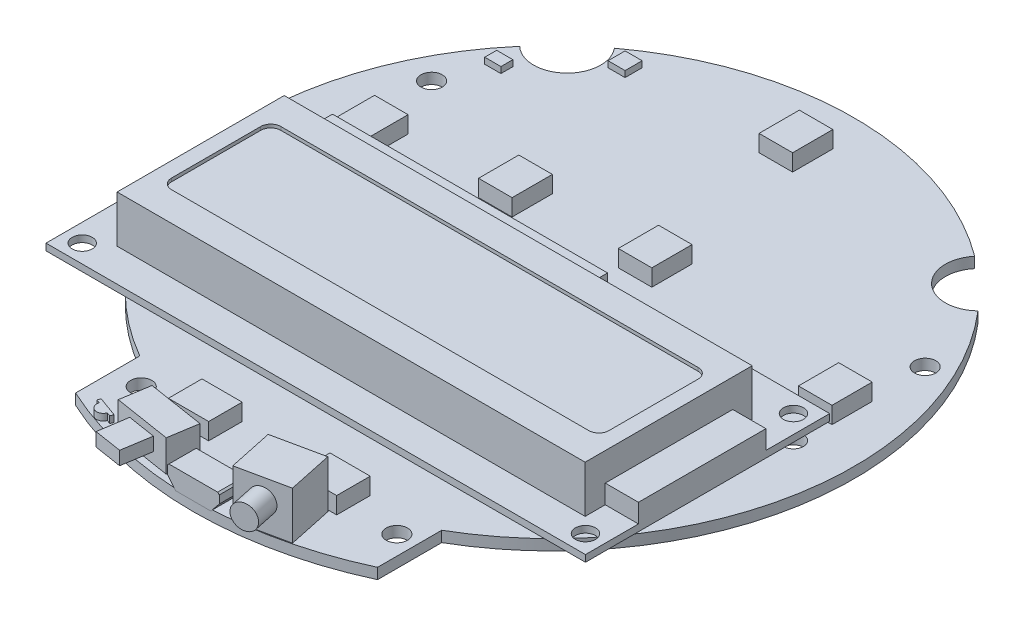
from build123d import *

# Parameters (mm, degrees)
BOSS_EXTRUDE_START                   = 29.4
PCB_AREA_R                           = 1.5
PCB_AREA_R_2                         = 1.59
BOSS_EXTRUDE_PCB_DEPTH               = 1.6
BOSS_EXTRUDE_START_2                 = 33.5
LCD_AREA_W                           = 80.4
LCD_AREA_H                           = 36.4
LCD_AREA_R                           = 1.5
BOSS_EXTRUDE_LCD_PCB_DEPTH           = 1
BOSS_EXTRUDE_START_3                 = 36.6
LCD_AREA_3_W                         = 41
LCD_AREA_3_H                         = 3.5
BOSS_EXTRUDE_LCD_HEADER_DEPTH        = 5.6
BOSS_EXTRUDE_START_4                 = 34.5
LCD_AREA_4_W                         = 4.95
LCD_AREA_4_H                         = 19
BOSS_EXTRUDE_LCD_BACKLIGHT_DEPTH     = 2.8
LCD_AREA_5_W                         = 69.75
LCD_AREA_5_H                         = 24.9
BOSS_EXTRUDE_LCD_CASING_DEPTH        = 7
CUT_EXTRUDE_START                    = 41.5
CUT_EXTRUDE_LCD_SCREEN_DEPTH         = 0.5
BOSS_EXTRUDE_START_5                 = 31
PCB_COMPONENTS_3_W                   = 5.00000016
PCB_COMPONENTS_3_H                   = 6.0000007
PCB_COMPONENTS_3_W_2                 = 6.0000007
PCB_COMPONENTS_3_H_2                 = 5.00000016
BOSS_EXTRUDE_LEDS_DEPTH              = 2.5
BOSS_EXTRUDE_CHARGING_LED_DEPTH      = 1
PCB_COMPONENTS_5_W                   = 2.413
PCB_COMPONENTS_5_H                   = 1.778
BOSS_EXTRUDE_LIGHT_SENSOR_DEPTH      = 0.91
PCB_COMPONENTS_6_W                   = 2.54
PCB_COMPONENTS_6_H                   = 2.54
BOSS_EXTRUDE_TEMP_SENSOR_DEPTH       = 0.91
BOSS_EXTRUDE_POWER_SWITCH_BASE_DEPTH = 4.7
BOSS_EXTRUDE_START_6                 = 32.6
BOSS_EXTRUDE_POWER_SWITCH_DEPTH      = 2
BOSS_EXTRUDE_START_7                 = 53.5
BOSS_EXTRUDE_USB_CONNECTOR_DEPTH     = 4.06
BOSS_EXTRUDE_BUTTON_BASE_DEPTH       = 7.1
BUTTON_CIRCLE_R                      = 1.8
BOSS_EXTRUDE_BUTTON_DEPTH            = 3.55


with BuildPart() as part:
    # PCB area → Boss-Extrude PCB (new body)
    with BuildSketch(Plane(origin=(0, 0, 0), x_dir=(1, 0, 0), z_dir=(0, 1, 0)).offset(BOSS_EXTRUDE_START)):
        with BuildLine():
            Line((-22.5, -48.538644398), (-22.5, -38.97114317))
            ThreePointArc((-22.5, -38.97114317), (-44.358674104, -7.570206849), (-34.1516032, 29.303037366))
            ThreePointArc((-34.1516032, 29.303037366), (-27.279934403, 29.254148065), (-26.849361228, 36.112488167))
            ThreePointArc((-26.849361228, 36.112488167), (0, 45), (26.849361228, 36.112488167))
            ThreePointArc((26.849361228, 36.112488167), (27.279934402, 29.254148065), (34.1516032, 29.303037366))
            ThreePointArc((34.1516032, 29.303037366), (44.358674104, -7.570206849), (22.5, -38.97114317))
            Line((22.5, -38.97114317), (22.5, -48.538644398))
            ThreePointArc((22.5, -48.538644398), (0, -53.5), (-22.5, -48.538644398))
        make_face()
        with Locations((-37.85, -1.2)):
            Circle(PCB_AREA_R, mode=Mode.SUBTRACT)
        with Locations((37.15, -1.2)):
            Circle(PCB_AREA_R, mode=Mode.SUBTRACT)
        with Locations((-18.44, -42.82)):
            Circle(PCB_AREA_R_2, mode=Mode.SUBTRACT)
        with Locations((19.66, -42.82)):
            Circle(PCB_AREA_R_2, mode=Mode.SUBTRACT)
        with Locations((-36.25, 18.27)):
            Circle(PCB_AREA_R_2, mode=Mode.SUBTRACT)
        with Locations((37.44, 18.14)):
            Circle(PCB_AREA_R_2, mode=Mode.SUBTRACT)
    extrude(amount=BOSS_EXTRUDE_PCB_DEPTH)



with BuildPart() as body_2:
    # LCD area → Boss-Extrude LCD PCB (new body)
    with BuildSketch(Plane(origin=(0, 0, 0), x_dir=(1, 0, 0), z_dir=(0, 1, 0)).offset(BOSS_EXTRUDE_START_2)):
        with Locations((-0.35, -16.7)):
            Rectangle(LCD_AREA_W, LCD_AREA_H)
        with Locations((-37.85, -1.2)):
            Circle(LCD_AREA_R, mode=Mode.SUBTRACT)
        with Locations((37.15, -1.2)):
            Circle(LCD_AREA_R, mode=Mode.SUBTRACT)
        with Locations((37.15, -32.2)):
            Circle(LCD_AREA_R, mode=Mode.SUBTRACT)
        with Locations((-37.85, -32.2)):
            Circle(LCD_AREA_R, mode=Mode.SUBTRACT)
    extrude(amount=BOSS_EXTRUDE_LCD_PCB_DEPTH)


with BuildPart() as part_1:
    add(part.part)

    add(body_2.part)  # Boss-Extrude LCD header merges body 2
    # LCD area_3 → Boss-Extrude LCD header (add)
    with BuildSketch(Plane(origin=(0, 0, 0), x_dir=(1, 0, 0), z_dir=(0, 1, 0)).offset(BOSS_EXTRUDE_START_3)):
        with Locations((-13.25, -0.75)):
            Rectangle(LCD_AREA_3_W, LCD_AREA_3_H)
    extrude(amount=-BOSS_EXTRUDE_LCD_HEADER_DEPTH)

    # LCD area_4 → Boss-Extrude LCD backlight (add)
    with BuildSketch(Plane(origin=(0, 0, 0), x_dir=(1, 0, 0), z_dir=(0, 1, 0)).offset(BOSS_EXTRUDE_START_4)):
        with Locations((37.375, -17.5)):
            Rectangle(LCD_AREA_4_W, LCD_AREA_4_H)
    extrude(amount=BOSS_EXTRUDE_LCD_BACKLIGHT_DEPTH)

    # LCD area_5 → Boss-Extrude LCD casing (add)
    with BuildSketch(Plane(origin=(0, 0, 0), x_dir=(1, 0, 0), z_dir=(0, 1, 0)).offset(BOSS_EXTRUDE_START_4)):
        with Locations((0.025, -17.55)):
            Rectangle(LCD_AREA_5_W, LCD_AREA_5_H)
    extrude(amount=BOSS_EXTRUDE_LCD_CASING_DEPTH)

    # LCD area_6 → Cut-Extrude LCD screen (cut)
    with BuildSketch(Plane(origin=(0, 0, 0), x_dir=(1, 0, 0), z_dir=(0, 1, 0)).offset(CUT_EXTRUDE_START)):
        with BuildLine():
            Line((31.1, -25.65), (-31.1, -25.65))
            ThreePointArc((-31.1, -25.65), (-32.160660172, -25.210660172), (-32.6, -24.15))
            Line((-32.6, -24.15), (-32.6, -10.85))
            ThreePointArc((-32.6, -10.85), (-32.160660172, -9.789339828), (-31.1, -9.35))
            Line((-31.1, -9.35), (31.1, -9.35))
            ThreePointArc((31.1, -9.35), (32.160660172, -9.789339828), (32.6, -10.85))
            Line((32.6, -10.85), (32.6, -24.15))
            ThreePointArc((32.6, -24.15), (32.160660172, -25.210660172), (31.1, -25.65))
        make_face()
    extrude(amount=-CUT_EXTRUDE_LCD_SCREEN_DEPTH, mode=Mode.SUBTRACT)

    # PCB components_3 → Boss-Extrude LEDs (add)
    with BuildSketch(Plane(origin=(0, 0, 0), x_dir=(1, 0, 0), z_dir=(0, 1, 0)).offset(BOSS_EXTRUDE_START_5)):
        with Locations((-33.64490509, 6.662364904)):
            Rectangle(PCB_COMPONENTS_3_W, PCB_COMPONENTS_3_H)
        with Locations((-9.402413685, -42.304616346)):
            Rectangle(PCB_COMPONENTS_3_W_2, PCB_COMPONENTS_3_H_2)
        with Locations((9.693556469, -42.318837537)):
            Rectangle(PCB_COMPONENTS_3_W_2, PCB_COMPONENTS_3_H_2)
        with Locations((-15.185287476, 9.703655188)):
            Rectangle(PCB_COMPONENTS_3_W, PCB_COMPONENTS_3_H)
        with Locations((4.286094666, 11.05569071)):
            Rectangle(PCB_COMPONENTS_3_W, PCB_COMPONENTS_3_H)
        with Locations((35.455097198, 6.737369482)):
            Rectangle(PCB_COMPONENTS_3_W, PCB_COMPONENTS_3_H)
        with Locations((-0.07787323, 36.401340429)):
            Rectangle(PCB_COMPONENTS_3_W, PCB_COMPONENTS_3_H)
    extrude(amount=BOSS_EXTRUDE_LEDS_DEPTH)

    # PCB components → Boss-Extrude charging LED (add)
    with BuildSketch(Plane(origin=(0, 0, 0), x_dir=(1, 0, 0), z_dir=(0, 1, 0)).offset(BOSS_EXTRUDE_START_5)):
        with BuildLine():
            Line((-19.015338568, -48.848593014), (-18.451523006, -49.053805147))
            ThreePointArc((-18.451523006, -49.053805147), (-17.853850615, -50.335517952), (-16.572137811, -49.737845561))
            Line((-16.572137811, -49.737845561), (-16.008322255, -49.943057676))
            Line((-16.008322255, -49.943057676), (-15.837312152, -49.473211377))
            Line((-15.837312152, -49.473211377), (-18.844328464, -48.378746715))
            Line((-18.844328464, -48.378746715), (-19.015338568, -48.848593014))
        make_face()
    extrude(amount=BOSS_EXTRUDE_CHARGING_LED_DEPTH)

    # PCB components_5 → Boss-Extrude light sensor (add)
    with BuildSketch(Plane(origin=(0, 0, 0), x_dir=(1, 0, 0), z_dir=(0, 1, 0)).offset(BOSS_EXTRUDE_START_5)):
        with Locations((-33.235496521, 25.269289599)):
            Rectangle(PCB_COMPONENTS_5_W, PCB_COMPONENTS_5_H)
    extrude(amount=BOSS_EXTRUDE_LIGHT_SENSOR_DEPTH)

    # PCB components_6 → Boss-Extrude temp sensor (add)
    with BuildSketch(Plane(origin=(0, 0, 0), x_dir=(1, 0, 0), z_dir=(0, 1, 0)).offset(BOSS_EXTRUDE_START_5)):
        with Locations((-23.527870178, 34.385096178)):
            Rectangle(PCB_COMPONENTS_6_W, PCB_COMPONENTS_6_H)
    extrude(amount=BOSS_EXTRUDE_TEMP_SENSOR_DEPTH)

    # PCB components_7 → Boss-Extrude power switch base (add)
    with BuildSketch(Plane(origin=(0, 0, 0), x_dir=(1, 0, 0), z_dir=(0, 1, 0)).offset(BOSS_EXTRUDE_START_5)):
        Polygon((-5.265972545, -52.267218464), (-13.760092303, -50.921882249), (-13.071780751, -46.576053535), (-4.577660993, -47.92138975), align=None)
    extrude(amount=BOSS_EXTRUDE_POWER_SWITCH_BASE_DEPTH)

    # PCB height map → Boss-Extrude USB connector (add)
    with BuildSketch(Plane.XY.offset(BOSS_EXTRUDE_START_7)):
        Polygon((-2.625, 30.8), (2.625, 30.8), (3.872091094, 32.337908906), (3.872091094, 33.507908906), (3.63, 33.75), (-3.63, 33.75), (-3.872091094, 33.507908906), (-3.872091094, 32.337908906), align=None)
    extrude(amount=-BOSS_EXTRUDE_USB_CONNECTOR_DEPTH)

    # PCB components_9 → Boss-Extrude button base (add)
    with BuildSketch(Plane(origin=(0, 0, 0), x_dir=(1, 0, 0), z_dir=(0, 1, 0)).offset(BOSS_EXTRUDE_START_5)):
        Polygon((4.288833513, -46.634785586), (11.624940357, -45.075447145), (13.046016326, -51.761080528), (5.709909482, -53.320418969), align=None)
    extrude(amount=BOSS_EXTRUDE_BUTTON_BASE_DEPTH)

    # Button circle → Boss-Extrude button (add)
    with BuildSketch(Plane(origin=(11.090513202, 0, 52.17673576), x_dir=(0.978147579, 0, -0.207911792), z_dir=(0.207911792, 0, 0.978147579))):
        with Locations((-1.750809729, 35.06)):
            Circle(BUTTON_CIRCLE_R)
    extrude(amount=BOSS_EXTRUDE_BUTTON_DEPTH)


with BuildPart() as body_2_2:
    # PCB components_8 → Boss-Extrude power switch (new body)
    with BuildSketch(Plane(origin=(0, 0, 0), x_dir=(1, 0, 0), z_dir=(0, 1, 0)).offset(BOSS_EXTRUDE_START_6)):
        Polygon((-7.537655758, -51.90741924), (-11.725118165, -51.244190443), (-12.394248337, -55.593057189), (-8.22596731, -56.253247953), align=None)
    extrude(amount=BOSS_EXTRUDE_POWER_SWITCH_DEPTH)


solid = Compound([part_1.part, body_2_2.part])
